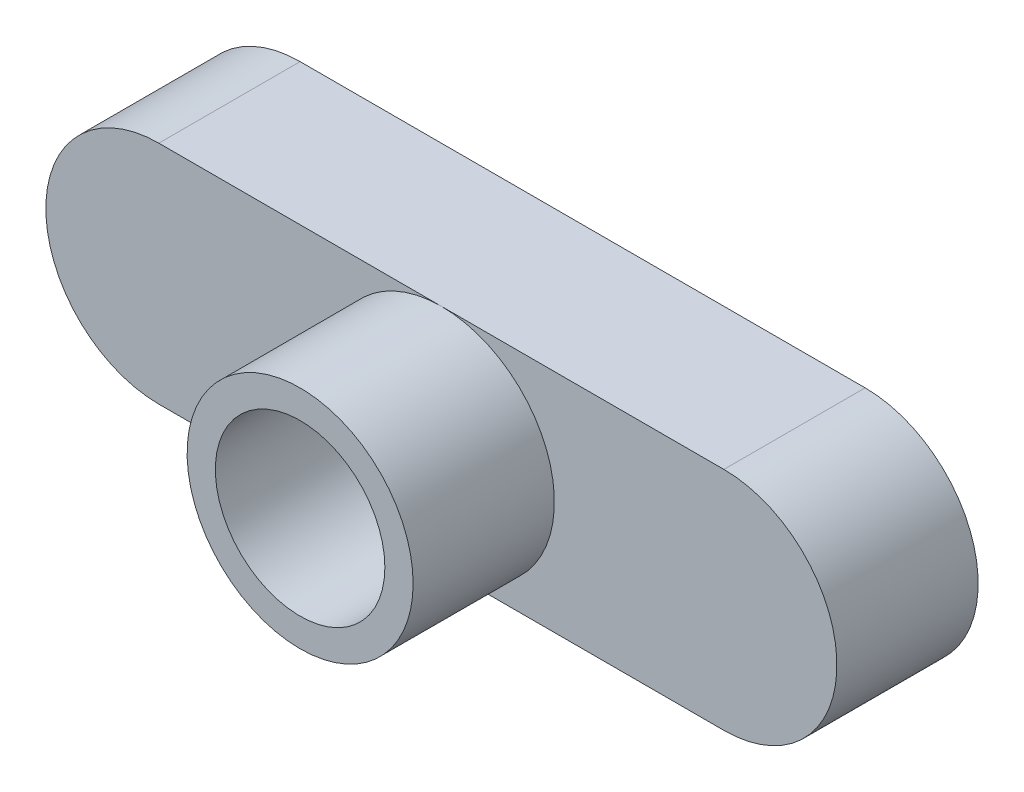
from build123d import *

# Parameters (mm, degrees)
SKETCH1_R           = 3
BOSS_EXTRUDE1_DEPTH = 5
SKETCH2_R           = 4
SKETCH2_R_2         = 3
BOSS_EXTRUDE2_DEPTH = 5


with BuildPart() as part:
    # Sketch1 → Boss-Extrude1 (new body)
    with BuildSketch(Plane.XY):
        with BuildLine():
            Line((-10, 4), (10, 4))
            ThreePointArc((10, 4), (14, 0), (10, -4))
            Line((10, -4), (-10, -4))
            ThreePointArc((-10, -4), (-14, 0), (-10, 4))
        make_face()
        Circle(SKETCH1_R, mode=Mode.SUBTRACT)
    extrude(amount=BOSS_EXTRUDE1_DEPTH)

    # Sketch2 → Boss-Extrude2 (add)
    with BuildSketch(Plane.XY.offset(5)):
        Circle(SKETCH2_R)
        Circle(SKETCH2_R_2, mode=Mode.SUBTRACT)
    extrude(amount=BOSS_EXTRUDE2_DEPTH)


solid = part.part
